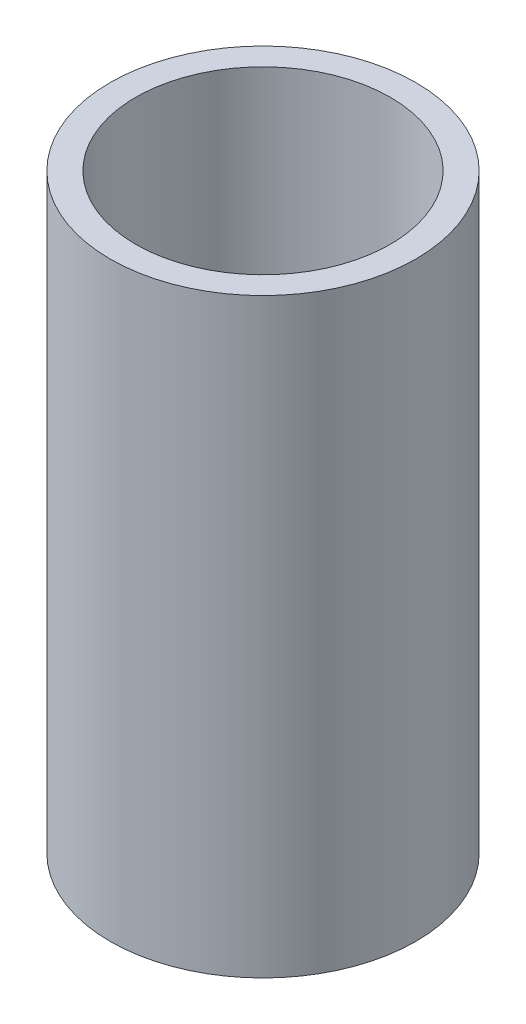
from build123d import *

# Parameters (mm, degrees)
CROQUIS1_W = 8.75
CROQUIS1_H = 203


with BuildPart() as part:
    # Croquis1 → Revolución1 (revolve)
    with BuildSketch(Plane.XY):
        with Locations((-48.125, 101.5)):
            Rectangle(CROQUIS1_W, CROQUIS1_H)
    revolve(axis=Axis((0, 0, 0), (0, 1, 0)))


solid = part.part
